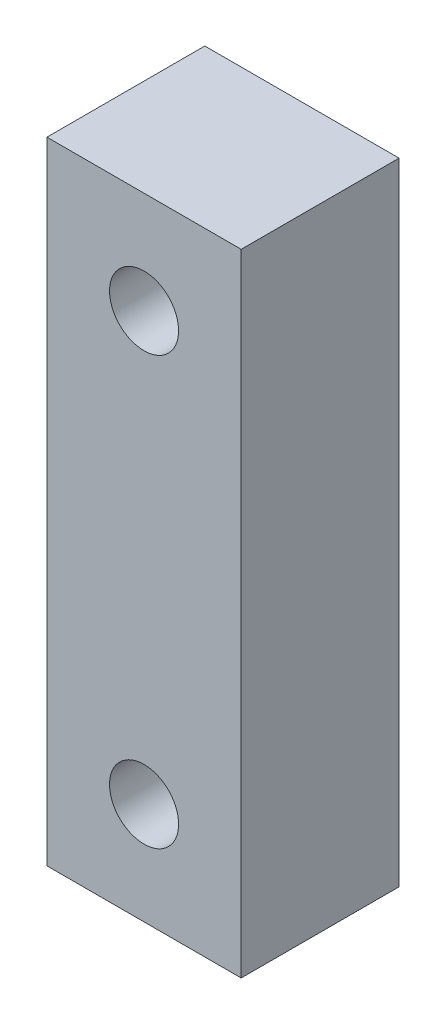
from build123d import *

# Parameters (mm, degrees)
ESBO_O1_W                = 5
ESBO_O1_H                = 16.245
ESBO_O1_R                = 0.889
RESSALTO_EXTRUS_O1_DEPTH = 4.064


with BuildPart() as part:
    # Esboço1 → Ressalto-extrusão1 (new body)
    with BuildSketch(Plane.XY.offset(4.064)):
        with Locations((2.5, 8.1225)):
            Rectangle(ESBO_O1_W, ESBO_O1_H)
        with Locations((2.5, 2.6225)):
            Circle(ESBO_O1_R, mode=Mode.SUBTRACT)
        with Locations((2.5, 13.6225)):
            Circle(ESBO_O1_R, mode=Mode.SUBTRACT)
    extrude(amount=-RESSALTO_EXTRUS_O1_DEPTH)


solid = part.part
